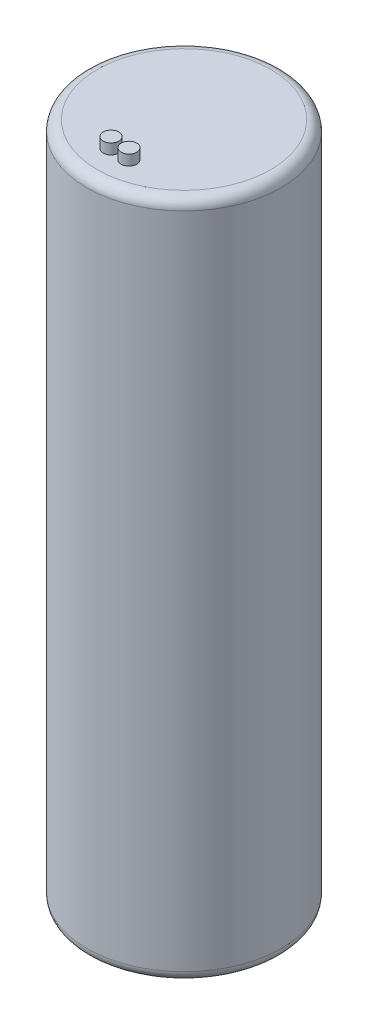
from build123d import *

# Parameters (mm, degrees)
SKETCH1_R           = 9.3
BOSS_EXTRUDE1_DEPTH = 65
FILLET1_R           = 1
SKETCH2_R           = 0.75
BOSS_EXTRUDE2_DEPTH = 1


with BuildPart() as part:
    # Sketch1 → Boss-Extrude1 (new body)
    with BuildSketch(Plane(origin=(0, 0, 0), x_dir=(1, 0, 0), z_dir=(0, 1, 0))):
        Circle(SKETCH1_R)
    extrude(amount=BOSS_EXTRUDE1_DEPTH)

    # Fillet1
    fillet1_edges = [part.edges().sort_by_distance(p)[0] for p in [
        (-9.3, 0, 0),
        (-9.3, 65, 0),
    ]]
    fillet(fillet1_edges, radius=FILLET1_R)

    # Sketch2 → Boss-Extrude2 (add)
    with BuildSketch(Plane(origin=(0, 65, 0), x_dir=(1, 0, 0), z_dir=(0, 1, 0))):
        with Locations((-1.089057168, -5.900335116)):
            Circle(SKETCH2_R)
        with Locations((0.694041569, -5.959723676)):
            Circle(SKETCH2_R)
    extrude(amount=BOSS_EXTRUDE2_DEPTH)


solid = part.part
